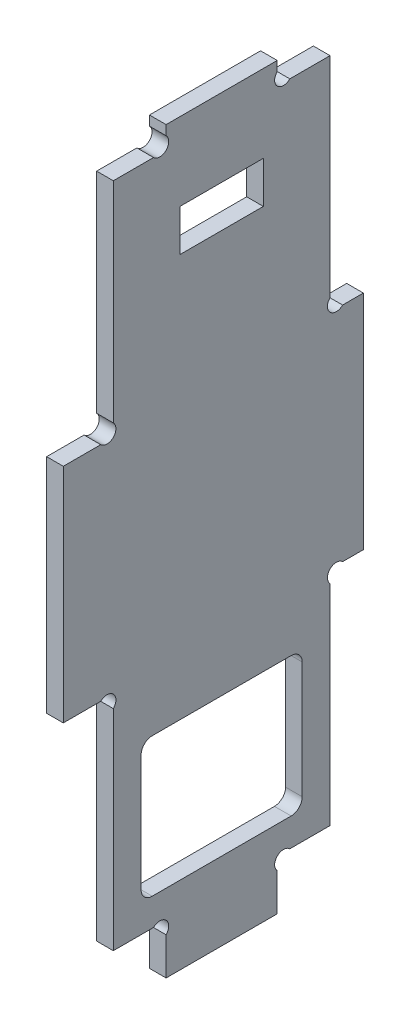
from build123d import *

# Parameters (mm, degrees)
EXTRUSION1_DEPTH        = 3
ESQUISSE2_W             = 29
ESQUISSE2_H             = 25
ENL_V_MAT_EXTRU_1_DEPTH = 4
CONG_1_R                = 2
ESQUISSE3_W             = 15
ESQUISSE3_H             = 7.5
ENL_V_MAT_EXTRU_2_DEPTH = 4


with BuildPart() as part:
    # Esquisse1 → Extrusion1 (new body)
    with BuildSketch(Plane(origin=(0, 0, 0), x_dir=(0, 0, -1), z_dir=(1, 0, 0))):
        with BuildLine():
            Line((18.5, 6.7372583), (18.5, 0))
            Line((18.5, 0), (38.5, 0))
            Line((38.5, 0), (38.5, 6.7372583))
            ThreePointArc((38.5, 6.7372583), (38.5, 9), (40.7627417, 9))
            Line((40.7627417, 9), (48, 9))
            Line((48, 9), (48, 46.7372583))
            ThreePointArc((48, 46.7372583), (48, 49), (50.2627417, 49))
            Line((50.2627417, 49), (54, 49))
            Line((54, 49), (54, 89))
            Line((54, 89), (50.2627417, 89))
            ThreePointArc((50.2627417, 89), (48, 89), (48, 91.2627417))
            Line((48, 91.2627417), (48, 129))
            Line((48, 129), (40.7627417, 129))
            ThreePointArc((40.7627417, 129), (38.5, 129), (38.5, 131.2627417))
            Line((38.5, 131.2627417), (38.5, 133))
            Line((38.5, 133), (18.5, 133))
            Line((18.5, 133), (18.5, 131.2627417))
            ThreePointArc((18.5, 131.2627417), (18.5, 129), (16.2372583, 129))
            Line((16.2372583, 129), (9, 129))
            Line((9, 129), (9, 91.2627417))
            ThreePointArc((9, 91.2627417), (9, 89), (6.7372583, 89))
            Line((6.7372583, 89), (0, 89))
            Line((0, 89), (0, 49))
            Line((0, 49), (6.7372583, 49))
            ThreePointArc((6.7372583, 49), (9, 49), (9, 46.7372583))
            Line((9, 46.7372583), (9, 9))
            Line((9, 9), (16.2372583, 9))
            ThreePointArc((16.2372583, 9), (18.5, 9), (18.5, 6.7372583))
        make_face()
    extrude(amount=EXTRUSION1_DEPTH)

    # Esquisse2 → Enlèv. mat.-Extru.1 (cut, through all)
    with BuildSketch(Plane(origin=(3, 0, 0), x_dir=(0, 0, -1), z_dir=(1, 0, 0))):
        with Locations((28.5, 26.5)):
            Rectangle(ESQUISSE2_W, ESQUISSE2_H)
    extrude(amount=-ENL_V_MAT_EXTRU_1_DEPTH, mode=Mode.SUBTRACT)

    # Congé1
    cong_1_edges = [part.edges().sort_by_distance(p)[0] for p in [
        (1.5, 14, -14),
        (1.5, 39, -14),
        (1.5, 39, -43),
        (1.5, 14, -43),
    ]]
    fillet(cong_1_edges, radius=CONG_1_R)

    # Esquisse3 → Enlèv. mat.-Extru.2 (cut, through all)
    with BuildSketch(Plane(origin=(3, 0, 0), x_dir=(0, 0, -1), z_dir=(1, 0, 0))):
        with Locations((28.5, 115.25)):
            Rectangle(ESQUISSE3_W, ESQUISSE3_H)
    extrude(amount=-ENL_V_MAT_EXTRU_2_DEPTH, mode=Mode.SUBTRACT)


solid = part.part
